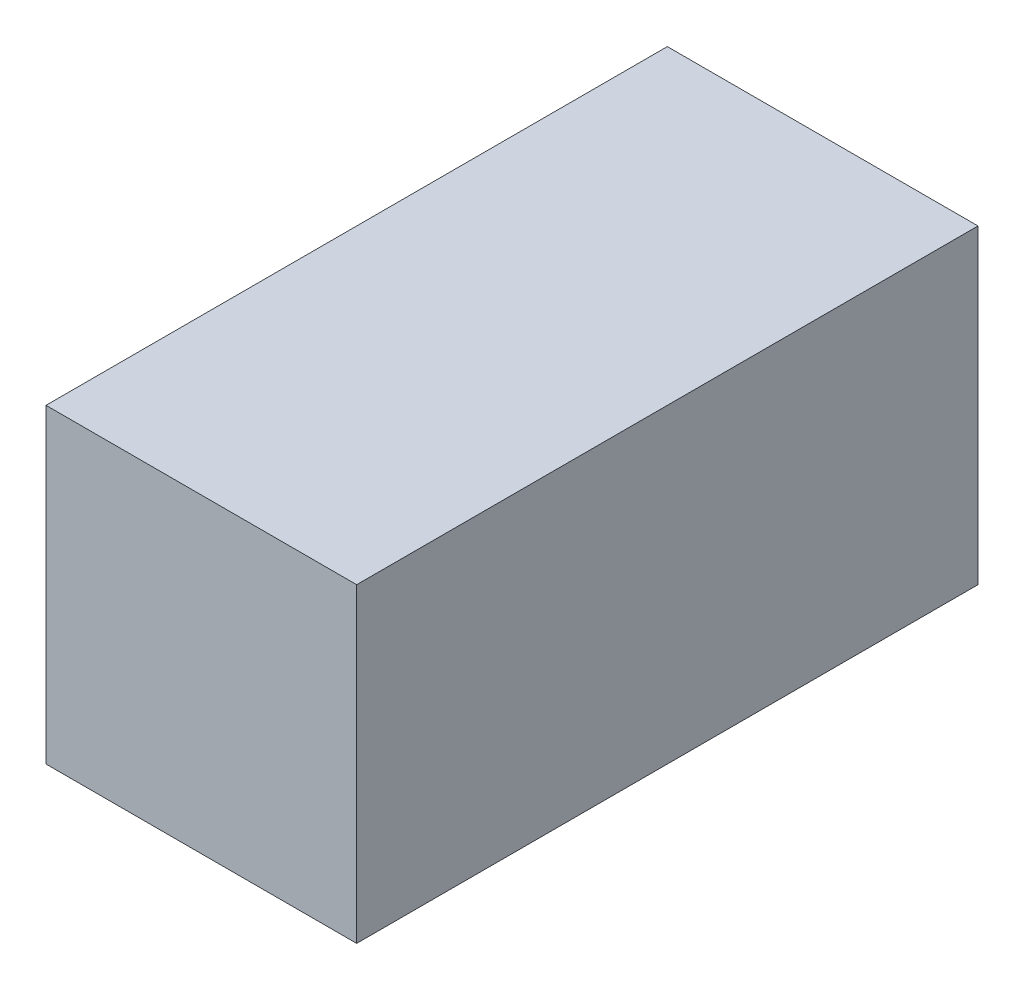
from build123d import *

# Parameters (mm, degrees)
CROQUIS1_W              = 500
CROQUIS1_H              = 500
SALIENTE_EXTRUIR1_DEPTH = 1000


with BuildPart() as part:
    # Croquis1 → Saliente-Extruir1 (new body)
    with BuildSketch(Plane.XY):
        Rectangle(CROQUIS1_W, CROQUIS1_H)
    extrude(amount=SALIENTE_EXTRUIR1_DEPTH)


solid = part.part
